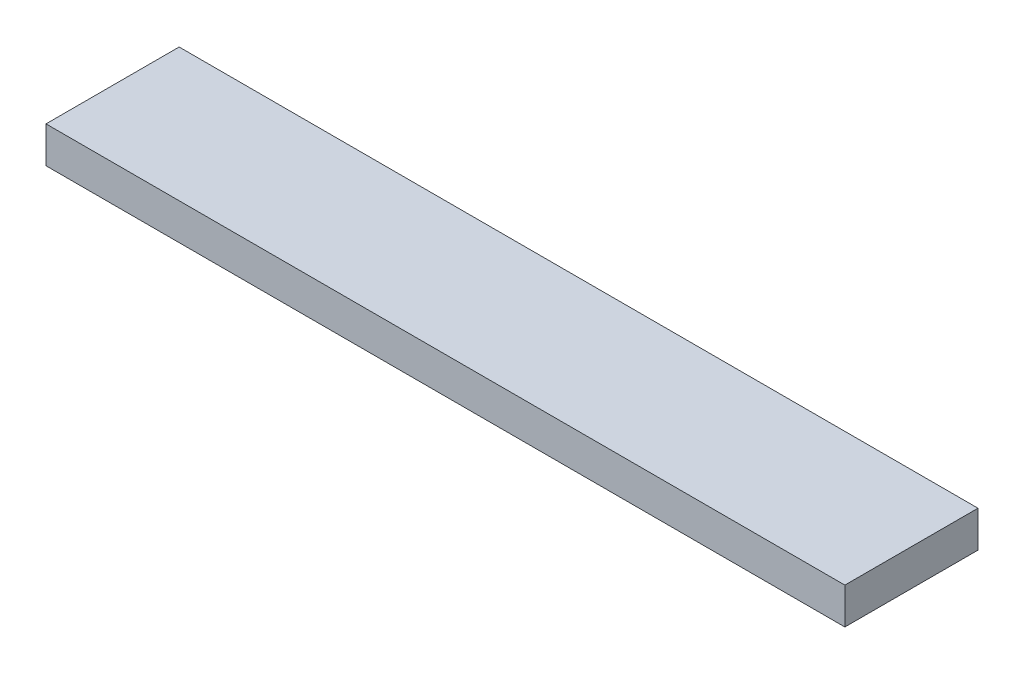
from build123d import *

# Parameters (mm, degrees)
SKETCH1_W           = 838.2
SKETCH1_H           = 139.7
BOSS_EXTRUDE1_DEPTH = 38.1


with BuildPart() as part:
    # Sketch1 → Boss-Extrude1 (new body)
    with BuildSketch(Plane(origin=(0, 0, 0), x_dir=(1, 0, 0), z_dir=(0, 1, 0))):
        with Locations((419.1, 69.85)):
            Rectangle(SKETCH1_W, SKETCH1_H)
    extrude(amount=BOSS_EXTRUDE1_DEPTH)


solid = part.part
